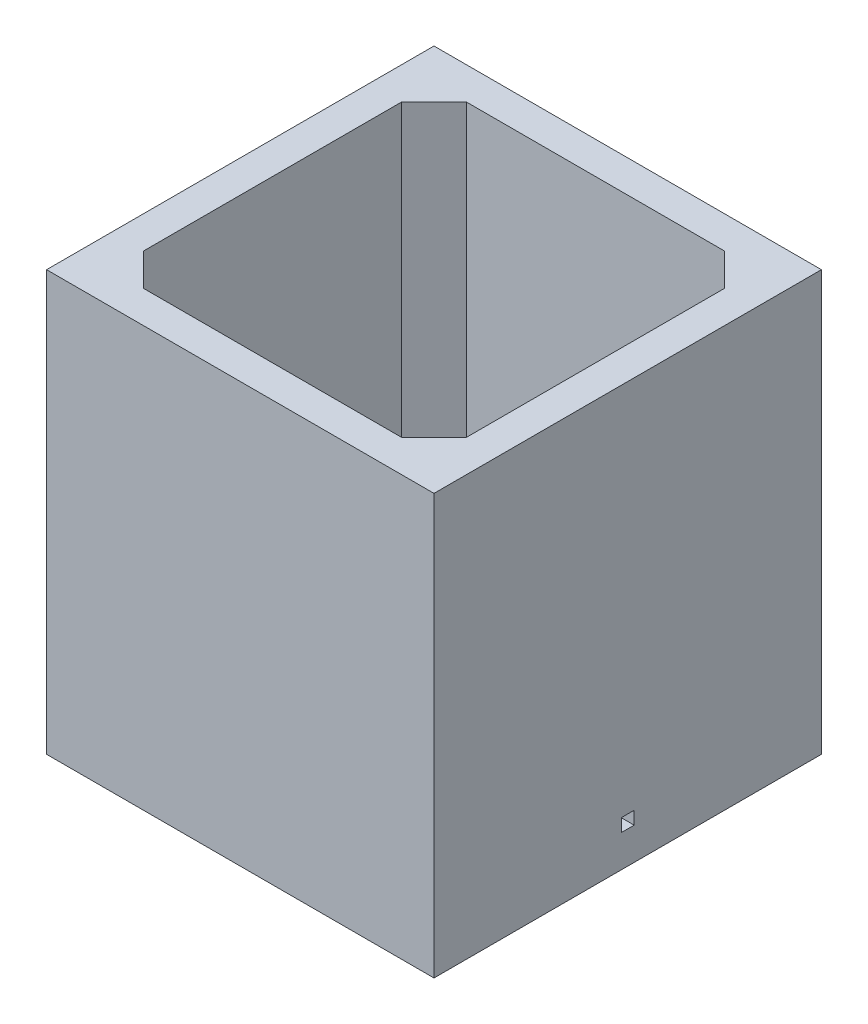
from build123d import *

# Parameters (mm, degrees)
SKETCH1_W           = 60
SKETCH1_H           = 60
SKETCH1_W_2         = 50
SKETCH1_H_2         = 50
BOSS_EXTRUDE1_DEPTH = 60
SKETCH2_W           = 60
SKETCH2_H           = 60
BOSS_EXTRUDE2_DEPTH = 5
SKETCH3_R           = 10
CUT_EXTRUDE1_DEPTH  = 6
CHAMFER4_SIZE       = 5
SKETCH7_W           = 2
SKETCH7_H           = 2
CUT_EXTRUDE3_DEPTH  = 5


with BuildPart() as part:
    # Sketch1 → Boss-Extrude1 (new body)
    with BuildSketch(Plane(origin=(0, 0, 0), x_dir=(1, 0, 0), z_dir=(0, 1, 0))):
        Rectangle(SKETCH1_W, SKETCH1_H)
        Rectangle(SKETCH1_W_2, SKETCH1_H_2, mode=Mode.SUBTRACT)
    extrude(amount=BOSS_EXTRUDE1_DEPTH)

    # Sketch2 → Boss-Extrude2 (add)
    with BuildSketch(Plane.XZ):
        Rectangle(SKETCH2_W, SKETCH2_H)
    extrude(amount=BOSS_EXTRUDE2_DEPTH)

    # Sketch3 → Cut-Extrude1 (cut, through all)
    with BuildSketch(Plane(origin=(0, 0, 0), x_dir=(1, 0, 0), z_dir=(0, 1, 0))):
        Circle(SKETCH3_R)
    extrude(amount=-CUT_EXTRUDE1_DEPTH, mode=Mode.SUBTRACT)

    # Chamfer4
    chamfer4_edges = [part.edges().sort_by_distance(p)[0] for p in [
        (25, 30, 25),
        (25, 30, -25),
        (-25, 30, -25),
        (-25, 30, 25),
    ]]
    chamfer(chamfer4_edges, length=CHAMFER4_SIZE)

    # Sketch7 → Cut-Extrude3 (cut)
    with BuildSketch(Plane.ZY.offset(-25)):
        with Locations((0, 1)):
            Rectangle(SKETCH7_W, SKETCH7_H)
    extrude(amount=-CUT_EXTRUDE3_DEPTH, mode=Mode.SUBTRACT)


solid = part.part
